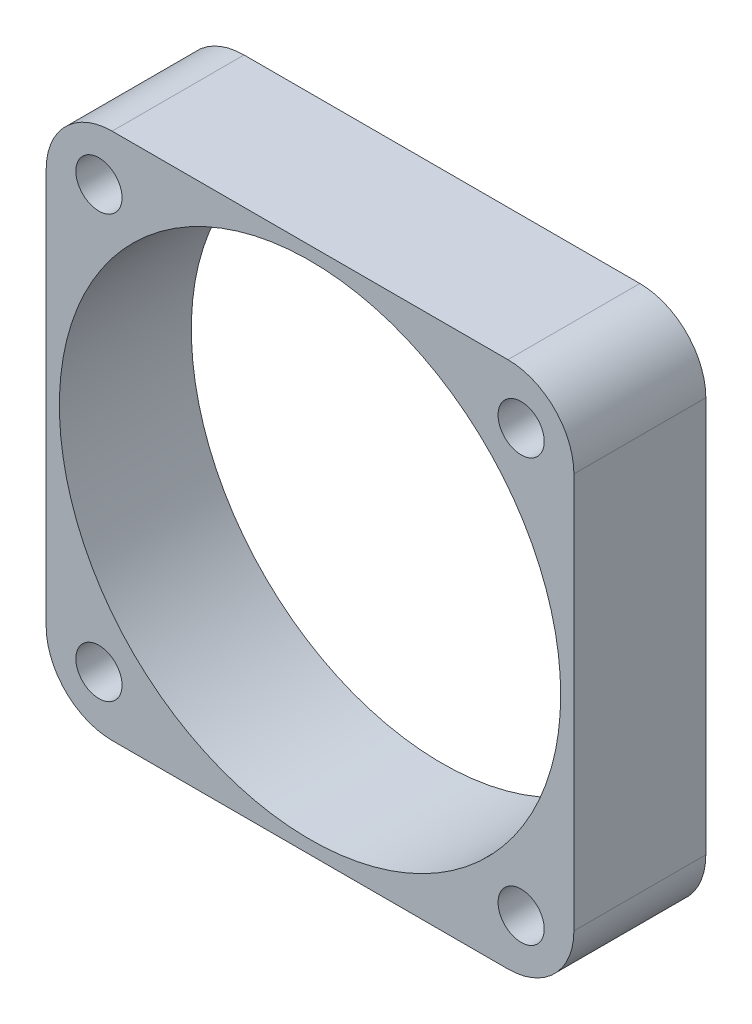
from build123d import *

# Parameters (mm, degrees)
SKETCH1_W           = 40
SKETCH1_H           = 40
BOSS_EXTRUDE1_DEPTH = 10
SKETCH3_R           = 19
SKETCH3_R_2         = 1.75
CUT_EXTRUDE1_DEPTH  = 10
FILLET1_R           = 5


with BuildPart() as part:
    # Sketch1 → Boss-Extrude1 (new body)
    with BuildSketch(Plane.XY):
        with Locations((20, 20)):
            Rectangle(SKETCH1_W, SKETCH1_H)
    extrude(amount=BOSS_EXTRUDE1_DEPTH)

    # Sketch3 → Cut-Extrude1 (cut)
    with BuildSketch(Plane.XY.offset(10)):
        with Locations((20, 20)):
            Circle(SKETCH3_R)
        with Locations((4, 36)):
            Circle(SKETCH3_R_2)
        with Locations((4, 4)):
            Circle(SKETCH3_R_2)
        with Locations((36, 4)):
            Circle(SKETCH3_R_2)
        with Locations((36, 36)):
            Circle(SKETCH3_R_2)
    extrude(amount=-CUT_EXTRUDE1_DEPTH, mode=Mode.SUBTRACT)

    # Fillet1
    fillet1_edges = [part.edges().sort_by_distance(p)[0] for p in [
        (0, 40, 5),
        (40, 40, 5),
        (40, 0, 5),
        (0, 0, 5),
    ]]
    fillet(fillet1_edges, radius=FILLET1_R)


solid = part.part
